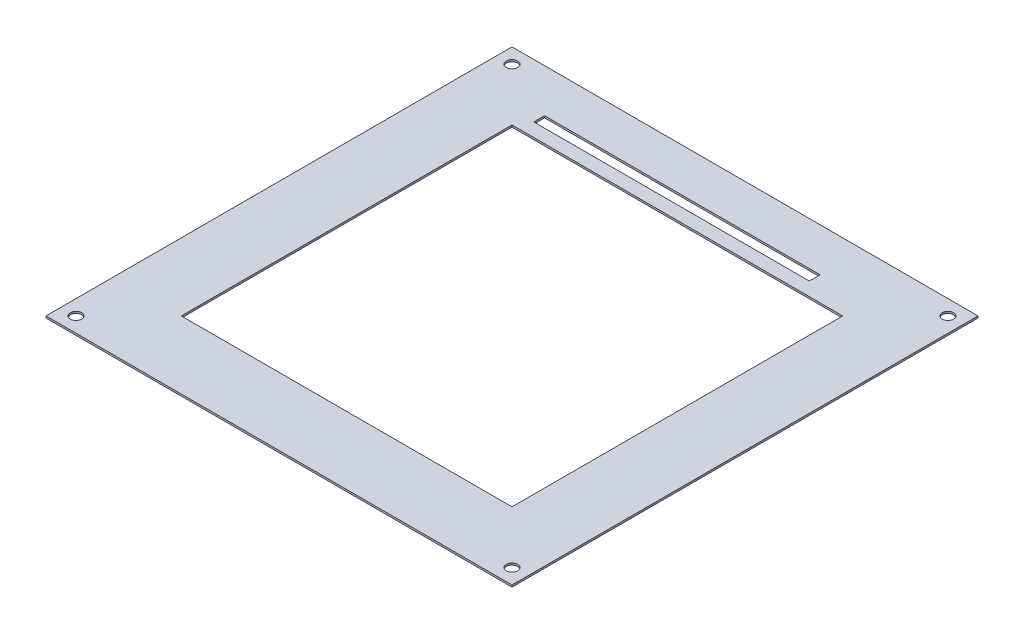
from build123d import *

# Parameters (mm, degrees)
SKETCH_1_W      = 124
SKETCH_1_H      = 124
SKETCH_1_R      = 1.5
SKETCH_1_W_2    = 88
SKETCH_1_H_2    = 88
SKETCH_1_W_3    = 73.332050418
SKETCH_1_H_3    = 2.87064966
EXTRUDE_1_DEPTH = 0.5


with BuildPart() as part:
    # Эскиз1 → Бобышка-Вытянуть1 (new body)
    with BuildSketch(Plane(origin=(0, 0, 0), x_dir=(1, 0, 0), z_dir=(0, 1, 0))):
        with Locations((62, 62)):
            Rectangle(SKETCH_1_W, SKETCH_1_H)
        with Locations((4, 120)):
            Circle(SKETCH_1_R, mode=Mode.SUBTRACT)
        with Locations((120, 120)):
            Circle(SKETCH_1_R, mode=Mode.SUBTRACT)
        with Locations((120, 4)):
            Circle(SKETCH_1_R, mode=Mode.SUBTRACT)
        with Locations((4, 4)):
            Circle(SKETCH_1_R, mode=Mode.SUBTRACT)
        with Locations((62, 62)):
            Rectangle(SKETCH_1_W_2, SKETCH_1_H_2, mode=Mode.SUBTRACT)
        with Locations((56.855908172, 111.032001236)):
            Rectangle(SKETCH_1_W_3, SKETCH_1_H_3, mode=Mode.SUBTRACT)
    extrude(amount=EXTRUDE_1_DEPTH)


solid = part.part
